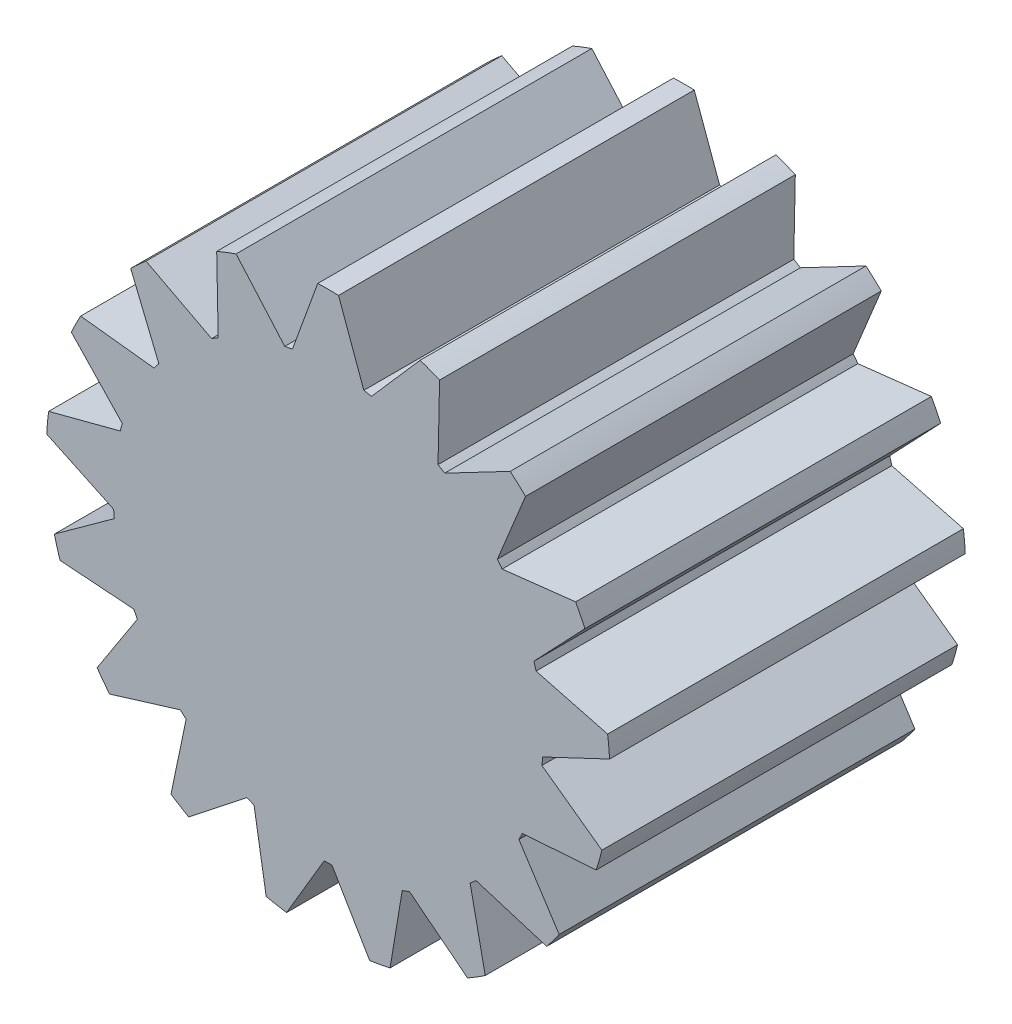
from build123d import *

# Parameters (mm, degrees)
BOSS_EXTRUDE1_DEPTH = 43.5102


with BuildPart() as part:
    # Sketch2 → Boss-Extrude1 (new body)
    with BuildSketch(Plane.XY):
        with BuildLine():
            Line((-4.366026501, 25.941944541), (-1.27, 34.448207442))
            ThreePointArc((-1.27, 34.448207442), (0, 34.47161), (1.27, 34.448207442))
            Line((1.27, 34.448207442), (4.366026501, 25.941944541))
            ThreePointArc((4.366026501, 25.941944541), (4.83385814, 25.858857079), (5.300112805, 25.767333549))
            Line((5.300112805, 25.767333549), (11.259888122, 32.580773709))
            ThreePointArc((11.259888122, 32.580773709), (12.452581833, 32.143819028), (13.628367585, 31.663219877))
            Line((13.628367585, 31.663219877), (13.442509735, 22.612952173))
            ThreePointArc((13.442509735, 22.612952173), (13.848735094, 22.366475142), (14.250442508, 22.11270138))
            Line((14.250442508, 22.11270138), (22.26906596, 26.31312595))
            ThreePointArc((22.26906596, 26.31312595), (23.223373486, 25.474827181), (24.14614861, 24.601939015))
            Line((24.14614861, 24.601939015), (20.703507542, 16.229955312))
            ThreePointArc((20.703507542, 16.229955312), (20.993263634, 15.8533768), (21.276170986, 15.471626358))
            Line((21.276170986, 15.471626358), (30.270683044, 16.491744725))
            ThreePointArc((30.270683044, 16.491744725), (30.857719866, 15.365318762), (31.402858467, 14.218029965))
            Line((31.402858467, 14.218029965), (25.168381933, 7.655013053))
            ThreePointArc((25.168381933, 7.655013053), (25.302535593, 7.199192074), (25.428434676, 6.741022466))
            Line((25.428434676, 6.741022466), (34.184076646, 4.443061991))
            ThreePointArc((34.184076646, 4.443061991), (34.324560189, 3.180638903), (34.418438279, 1.913897183))
            Line((34.418438279, 1.913897183), (26.234126882, -1.953781138))
            ThreePointArc((26.234126882, -1.953781138), (26.194559914, -2.427283433), (26.14644736, -2.899993864))
            Line((26.14644736, -2.899993864), (33.480721277, -8.205680884))
            ThreePointArc((33.480721277, -8.205680884), (33.155678459, -9.433603865), (32.785617282, -10.648718018))
            Line((32.785617282, -10.648718018), (23.756807626, -11.298706359))
            ThreePointArc((23.756807626, -11.298706359), (23.54886377, -11.725940863), (23.333237446, -12.149349953))
            Line((23.333237446, -12.149349953), (28.255608976, -19.746201087))
            ThreePointArc((28.255608976, -19.746201087), (27.508938632, -20.773786158), (26.724917, -21.773164845))
            Line((26.724917, -21.773164845), (18.07099986, -19.117678678))
            ThreePointArc((18.07099986, -19.117678678), (17.722763084, -19.440945003), (17.36874452, -19.757869009))
            Line((17.36874452, -19.757869009), (19.214420114, -28.619887416))
            ThreePointArc((19.214420114, -28.619887416), (18.14696421, -29.308353518), (17.054868589, -29.95702511))
            Line((17.054868589, -29.95702511), (9.944603428, -24.354702557))
            ThreePointArc((9.944603428, -24.354702557), (9.503105039, -24.530341795), (9.058506404, -24.697978373))
            Line((9.058506404, -24.697978373), (7.578217344, -33.628299361))
            ThreePointArc((7.578217344, -33.628299361), (6.334141716, -33.884665333), (5.081465671, -34.095023136))
            Line((5.081465671, -34.095023136), (0.475133198, -26.302488901))
            ThreePointArc((0.475133198, -26.302488901), (0, -26.30678), (-0.475133198, -26.302488901))
            Line((-0.475133198, -26.302488901), (-5.081465671, -34.095023136))
            ThreePointArc((-5.081465671, -34.095023136), (-6.334141716, -33.884665333), (-7.578217344, -33.628299361))
            Line((-7.578217344, -33.628299361), (-9.058506404, -24.697978373))
            ThreePointArc((-9.058506404, -24.697978373), (-9.503105039, -24.530341795), (-9.944603428, -24.354702557))
            Line((-9.944603428, -24.354702557), (-17.054868589, -29.95702511))
            ThreePointArc((-17.054868589, -29.95702511), (-18.14696421, -29.308353518), (-19.214420114, -28.619887416))
            Line((-19.214420114, -28.619887416), (-17.36874452, -19.757869009))
            ThreePointArc((-17.36874452, -19.757869009), (-17.722763084, -19.440945003), (-18.07099986, -19.117678678))
            Line((-18.07099986, -19.117678678), (-26.724917, -21.773164845))
            ThreePointArc((-26.724917, -21.773164845), (-27.508938632, -20.773786158), (-28.255608976, -19.746201087))
            Line((-28.255608976, -19.746201087), (-23.333237446, -12.149349953))
            ThreePointArc((-23.333237446, -12.149349953), (-23.54886377, -11.725940863), (-23.756807626, -11.298706359))
            Line((-23.756807626, -11.298706359), (-32.785617282, -10.648718018))
            ThreePointArc((-32.785617282, -10.648718018), (-33.155678459, -9.433603865), (-33.480721277, -8.205680884))
            Line((-33.480721277, -8.205680884), (-26.14644736, -2.899993864))
            ThreePointArc((-26.14644736, -2.899993864), (-26.194559914, -2.427283433), (-26.234126882, -1.953781138))
            Line((-26.234126882, -1.953781138), (-34.418438279, 1.913897183))
            ThreePointArc((-34.418438279, 1.913897183), (-34.324560189, 3.180638903), (-34.184076646, 4.443061991))
            Line((-34.184076646, 4.443061991), (-25.428434676, 6.741022466))
            ThreePointArc((-25.428434676, 6.741022466), (-25.302535593, 7.199192074), (-25.168381933, 7.655013053))
            Line((-25.168381933, 7.655013053), (-31.402858467, 14.218029965))
            ThreePointArc((-31.402858467, 14.218029965), (-30.857719866, 15.365318762), (-30.270683044, 16.491744725))
            Line((-30.270683044, 16.491744725), (-21.276170986, 15.471626358))
            ThreePointArc((-21.276170986, 15.471626358), (-20.993263634, 15.8533768), (-20.703507542, 16.229955312))
            Line((-20.703507542, 16.229955312), (-24.14614861, 24.601939015))
            ThreePointArc((-24.14614861, 24.601939015), (-23.223373486, 25.474827181), (-22.26906596, 26.31312595))
            Line((-22.26906596, 26.31312595), (-14.250442508, 22.11270138))
            ThreePointArc((-14.250442508, 22.11270138), (-13.848735094, 22.366475142), (-13.442509735, 22.612952173))
            Line((-13.442509735, 22.612952173), (-13.628367585, 31.663219877))
            ThreePointArc((-13.628367585, 31.663219877), (-12.452581833, 32.143819028), (-11.259888122, 32.580773709))
            Line((-11.259888122, 32.580773709), (-5.300112805, 25.767333549))
            ThreePointArc((-5.300112805, 25.767333549), (-4.83385814, 25.858857079), (-4.366026501, 25.941944541))
        make_face()
    extrude(amount=BOSS_EXTRUDE1_DEPTH)


solid = part.part
